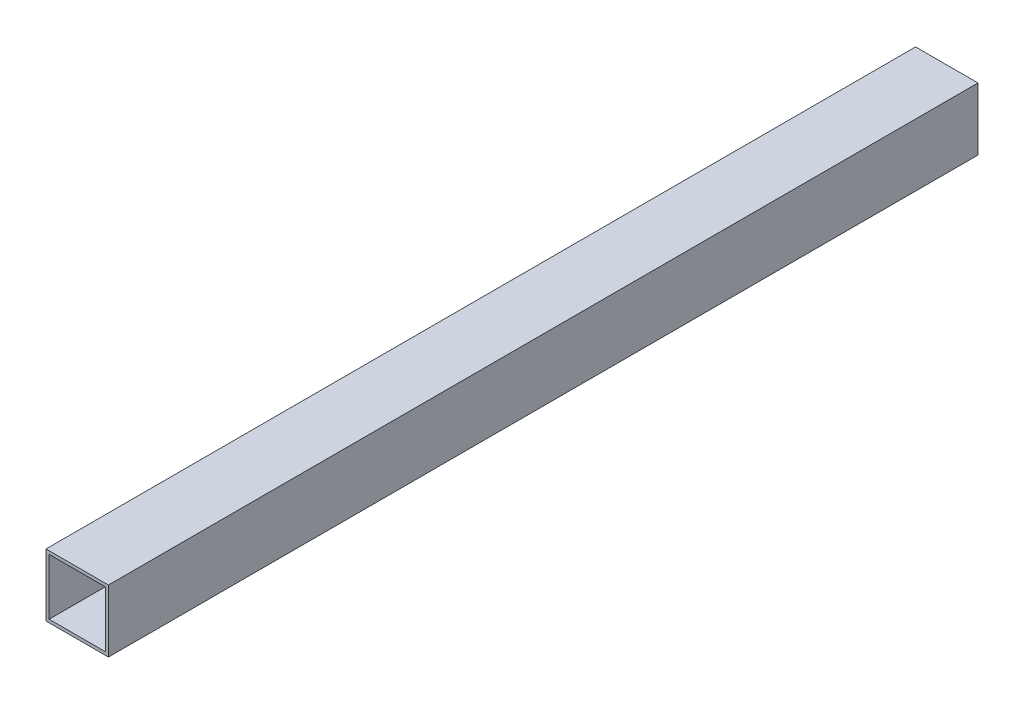
from build123d import *

# Parameters (mm, degrees)
SKETCH_1_W      = 20
SKETCH_1_H      = 20
SKETCH_1_W_2    = 18
SKETCH_1_H_2    = 18
EXTRUDE_1_DEPTH = 278.56


with BuildPart() as part:
    # 草图1 → 凸台-拉伸1 (new body)
    with BuildSketch(Plane.XY):
        Rectangle(SKETCH_1_W, SKETCH_1_H)
        Rectangle(SKETCH_1_W_2, SKETCH_1_H_2, mode=Mode.SUBTRACT)
    extrude(amount=EXTRUDE_1_DEPTH)


solid = part.part
